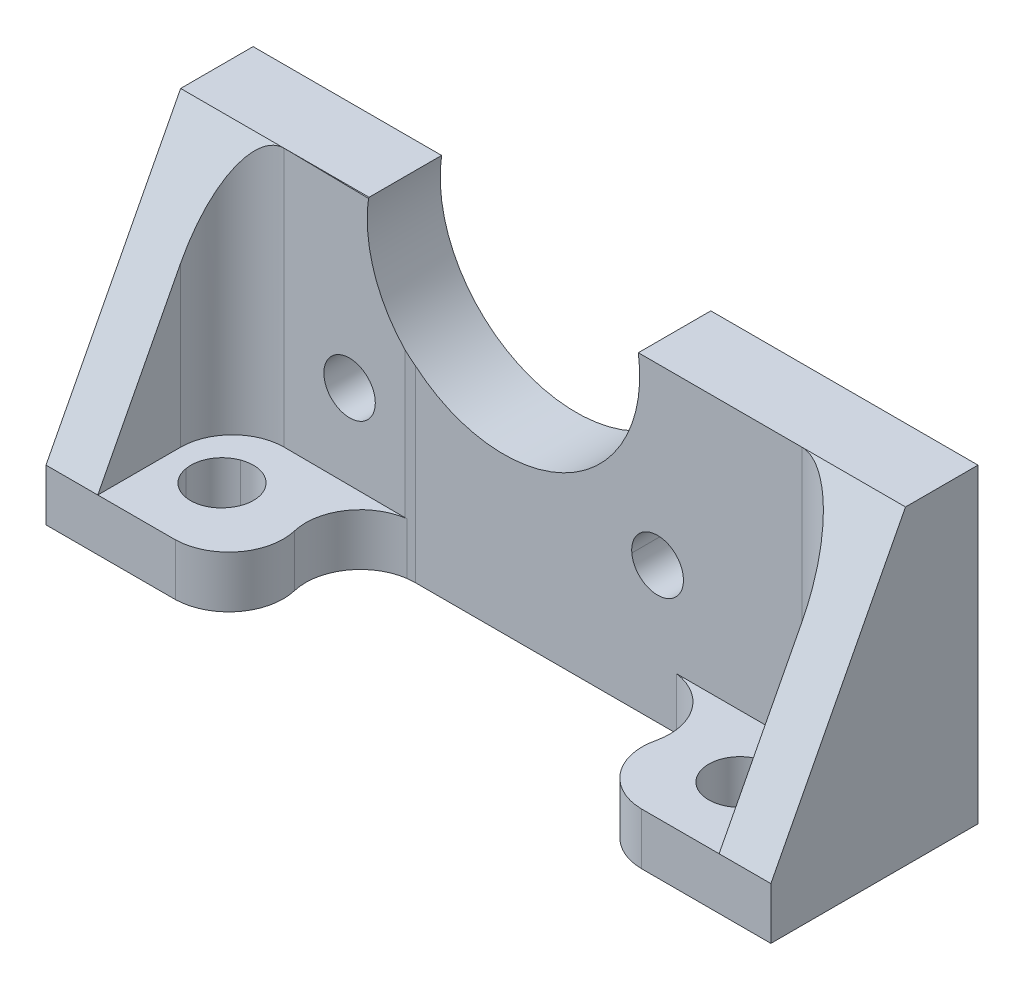
from build123d import *

# Parameters (mm, degrees)
SKETCH1_W           = 70
SKETCH1_H           = 30
BOSS_EXTRUDE1_DEPTH = 20
CUT_EXTRUDE2_DEPTH  = 21
CUT_EXTRUDE3_DEPTH  = 71
CUT_EXTRUDE7_DEPTH  = 31
BOSS_EXTRUDE3_DEPTH = 5
CUT_EXTRUDE8_DEPTH  = 71


with BuildPart() as part:
    # Sketch1 → Boss-Extrude1 (new body)
    with BuildSketch(Plane.XY):
        with Locations((-35, 15)):
            Rectangle(SKETCH1_W, SKETCH1_H)
    boss_extrude1 = extrude(amount=BOSS_EXTRUDE1_DEPTH)

    # Sketch1_3 → Cut-Extrude2 (cut, through all)
    with BuildSketch(Plane.XY):
        with BuildLine():
            Line((-18.200000763, 30), (-44.200000763, 30))
            ThreePointArc((-44.200000763, 30), (-31.200000763, 15), (-18.200000763, 30))
        make_face()
        with BuildLine():
            ThreePointArc((-15.706172943, 15.55638361), (-14.370568008, 14.668173822), (-13.850757599, 13.150756836))
            ThreePointArc((-13.850757599, 13.150756836), (-18.325338895, 11.617932335), (-15.706172943, 15.55638361))
        make_face()
        with BuildLine():
            ThreePointArc((-45.615119934, 15.61277771), (-44.064114621, 14.676308172), (-43.56823349, 12.933696747))
            ThreePointArc((-43.56823349, 12.933696747), (-48.042503261, 11.636717399), (-45.615119934, 15.61277771))
        make_face()
    cut_extrude2 = extrude(amount=CUT_EXTRUDE2_DEPTH, mode=Mode.SUBTRACT)

    # Sketch2 → Cut-Extrude3 (cut, through all)
    with BuildSketch(Plane.ZY.offset(70)):
        Polygon((20, 30), (7, 30), (20, 5), align=None)
    cut_extrude3 = extrude(amount=-CUT_EXTRUDE3_DEPTH, mode=Mode.SUBTRACT)

    # Mirror1: Boss-Extrude1, Cut-Extrude2, Cut-Extrude3 across plane
    add(boss_extrude1.mirror(Plane(origin=(0, 30, 20), x_dir=(0, 0, 1), z_dir=(1, 0, 0))))
    add(cut_extrude2.mirror(Plane(origin=(0, 30, 20), x_dir=(0, 0, 1), z_dir=(1, 0, 0))), mode=Mode.SUBTRACT)
    add(cut_extrude3.mirror(Plane(origin=(0, 30, 20), x_dir=(0, 0, 1), z_dir=(1, 0, 0))), mode=Mode.SUBTRACT)

    # Sketch4 → Cut-Extrude7 (cut, through all)
    with BuildSketch(Plane(origin=(0, 0, 0), x_dir=(1, 0, 0), z_dir=(0, 1, 0))):
        with BuildLine():
            Line((5, -11.999999865), (5, -20))
            Line((5, -20), (65, -20))
            Line((65, -20), (65, -12))
            ThreePointArc((65, -12), (63.535533906, -8.464466094), (60, -7))
            Line((60, -7), (22.686811447, -7))
            Line((22.686811447, -7), (21.717826843, -7.061558247))
            Line((21.717826843, -7.061558247), (10, -7))
            ThreePointArc((10, -7), (6.464466102, -8.464466007), (5, -11.999999865))
        make_face()
    extrude(amount=CUT_EXTRUDE7_DEPTH, mode=Mode.SUBTRACT)

    # Sketch4_6 → Boss-Extrude3 (add)
    with BuildSketch(Plane(origin=(0, 0, 0), x_dir=(1, 0, 0), z_dir=(0, 1, 0))):
        with BuildLine():
            Line((57.5, -20), (65, -20))
            Line((65, -20), (65, -12))
            ThreePointArc((65, -12), (63.535533906, -8.464466094), (60, -7))
            Line((60, -7), (47.881000272, -7))
            ThreePointArc((47.881000272, -7), (51.610779808, -9.240727474), (52.5, -13.5))
            ThreePointArc((52.5, -13.5), (53.428531793, -17.958821698), (57.5, -20))
        make_face()
        with BuildLine():
            ThreePointArc((58.071636237, -15.298134071), (57.54254335, -11.279271131), (61.499999792, -10.401924497))
            ThreePointArc((61.499999792, -10.401924497), (62.999999734, -13.000000826), (61.499999759, -15.598077136))
            ThreePointArc((61.499999759, -15.598077136), (59.738532149, -15.988585106), (58.071636237, -15.298134071))
        make_face(mode=Mode.SUBTRACT)
        with BuildLine():
            Line((5, -11.999999865), (5, -20))
            Line((5, -20), (12.5, -20))
            ThreePointArc((12.5, -20), (16.552378538, -17.944137337), (17.5, -13.5))
            ThreePointArc((17.5, -13.5), (18.286173232, -9.293081984), (21.929830501, -7.048089949))
            Line((21.929830501, -7.048089949), (21.717826843, -7.061558247))
            Line((21.717826843, -7.061558247), (10, -7))
            ThreePointArc((10, -7), (6.464466102, -8.464466007), (5, -11.999999865))
        make_face()
        with BuildLine():
            ThreePointArc((7.045577049, -13.520944595), (7.401923496, -11.500000278), (8.973938942, -10.180922508))
            ThreePointArc((8.973938942, -10.180922508), (12.387007699, -11.175196953), (12.37415177, -14.730116746))
            ThreePointArc((12.37415177, -14.730116746), (9.302656578, -15.920012423), (7.045577049, -13.520944595))
        make_face(mode=Mode.SUBTRACT)
    extrude(amount=BOSS_EXTRUDE3_DEPTH)

    # Sketch11 → Cut-Extrude8 (cut, through all)
    with BuildSketch(Plane(origin=(0, 0, 0), x_dir=(0, 0, -1), z_dir=(1, 0, 0))):
        Polygon((-20, 0), (0, 0), (0, 30), (-7, 30), (-20, 5), align=None)
    extrude(amount=-CUT_EXTRUDE8_DEPTH, mode=Mode.SUBTRACT)


solid = part.part
